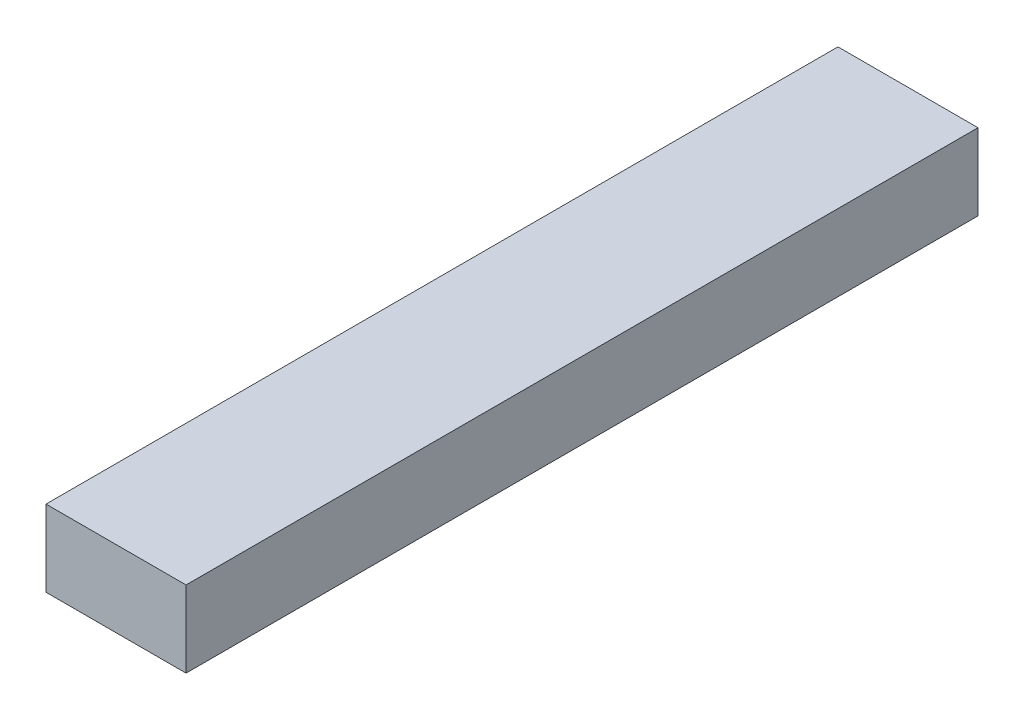
from build123d import *

# Parameters (mm, degrees)
SKETCH_1_W      = 55
SKETCH_1_H      = 311
EXTRUDE_1_DEPTH = 30


with BuildPart() as part:
    # Эскиз1 → Бобышка-Вытянуть1 (new body)
    with BuildSketch(Plane(origin=(0, 0, 0), x_dir=(1, 0, 0), z_dir=(0, 1, 0))):
        with Locations((27.5, 155.5)):
            Rectangle(SKETCH_1_W, SKETCH_1_H)
    extrude(amount=EXTRUDE_1_DEPTH)


solid = part.part
